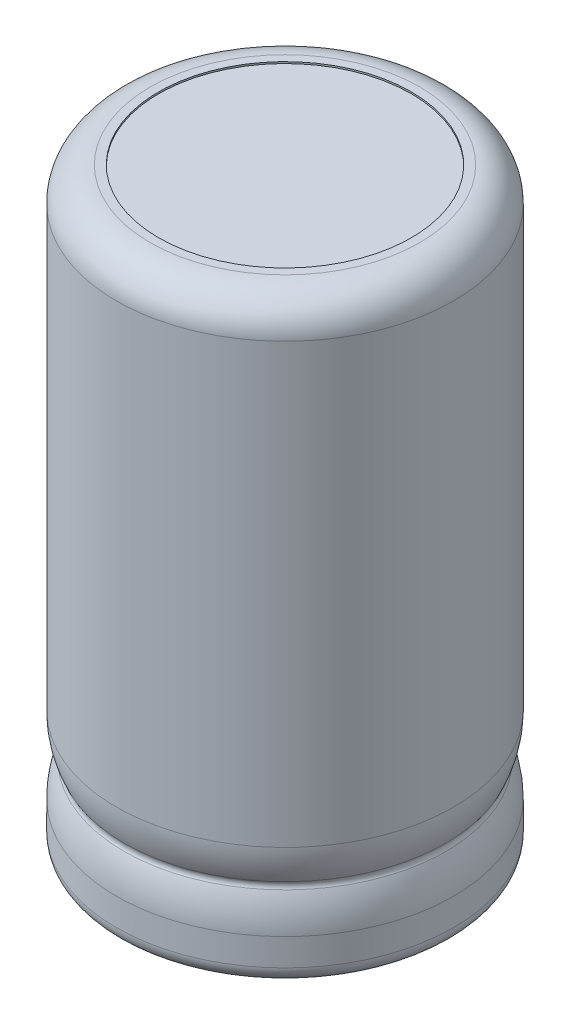
from build123d import *

# Parameters (mm, degrees)
SKETCH1_R           = 0.5
BASE_EXTRUDE_DEPTH  = 3
SKETCH2_R           = 7.5
BOSS_EXTRUDE1_DEPTH = 0.690752369
SKETCH3_R           = 0.5
BOSS_EXTRUDE2_DEPTH = 3
SKETCH4_R           = 10
BOSS_EXTRUDE3_DEPTH = 35.2
SKETCH5_R           = 7.5
SKETCH5_R_2         = 0.5
CUT_EXTRUDE1_DEPTH  = 0.1
FILLET1_R           = 2
FILLET2_R           = 1
SKETCH7_R           = 7.5
CUT_EXTRUDE2_DEPTH  = 0.1


with BuildPart() as part:
    # Sketch1 → Base-Extrude (new body)
    with BuildSketch(Plane(origin=(0, 0, 0), x_dir=(1, 0, 0), z_dir=(0, 1, 0))):
        Circle(SKETCH1_R)
    extrude(amount=-BASE_EXTRUDE_DEPTH)

    # Sketch2 → Boss-Extrude1 (add)
    with BuildSketch(Plane(origin=(0, 0, 0), x_dir=(1, 0, 0), z_dir=(0, 1, 0))):
        with Locations((-5.08, 0)):
            Circle(SKETCH2_R)
    extrude(amount=BOSS_EXTRUDE1_DEPTH)

    # Sketch3 → Boss-Extrude2 (add)
    with BuildSketch(Plane.XZ):
        with Locations((-10.16, 0)):
            Circle(SKETCH3_R)
    extrude(amount=BOSS_EXTRUDE2_DEPTH)

    # Sketch4 → Boss-Extrude3 (add)
    with BuildSketch(Plane.XZ):
        with Locations((-5.08, 0)):
            Circle(SKETCH4_R)
    extrude(amount=-BOSS_EXTRUDE3_DEPTH)

    # Sketch5 → Cut-Extrude1 (cut)
    with BuildSketch(Plane.XZ):
        with Locations((-5.08, 0)):
            Circle(SKETCH5_R)
        Circle(SKETCH5_R_2, mode=Mode.SUBTRACT)
        with Locations((-10.16, 0)):
            Circle(SKETCH5_R_2, mode=Mode.SUBTRACT)
    extrude(amount=-CUT_EXTRUDE1_DEPTH, mode=Mode.SUBTRACT)

    # Fillet1
    fillet1_edges = [part.edges().sort_by_distance(p)[0] for p in [
        (-15.08, 35.2, 0),
    ]]
    fillet(fillet1_edges, radius=FILLET1_R)

    # Fillet2
    fillet2_edges = [part.edges().sort_by_distance(p)[0] for p in [
        (-15.08, 0, 0),
    ]]
    fillet(fillet2_edges, radius=FILLET2_R)

    # Sketch6 → Cut-Revolve1 (revolve, cut)
    with BuildSketch(Plane.XY):
        with BuildLine():
            Line((4.92, 7.19), (5.42, 7.19))
            Line((5.42, 7.19), (5.42, 2.61))
            Line((5.42, 2.61), (4.92, 2.61))
            ThreePointArc((4.92, 2.61), (4.804920837, 3.674592058), (4.465, 4.69))
            ThreePointArc((4.465, 4.69), (4.398803332, 4.9), (4.465, 5.11))
            ThreePointArc((4.465, 5.11), (4.804920837, 6.125407942), (4.92, 7.19))
        make_face()
    revolve(axis=Axis((-5.08, 0, 0), (0, 1, 0)), mode=Mode.SUBTRACT)

    # Sketch7 → Cut-Extrude2 (cut)
    with BuildSketch(Plane(origin=(0, 35.2, 0), x_dir=(-1, 0, 0), z_dir=(0, 1, 0))):
        with Locations((5.08, 0)):
            Circle(SKETCH7_R)
    extrude(amount=-CUT_EXTRUDE2_DEPTH, mode=Mode.SUBTRACT)


solid = part.part
